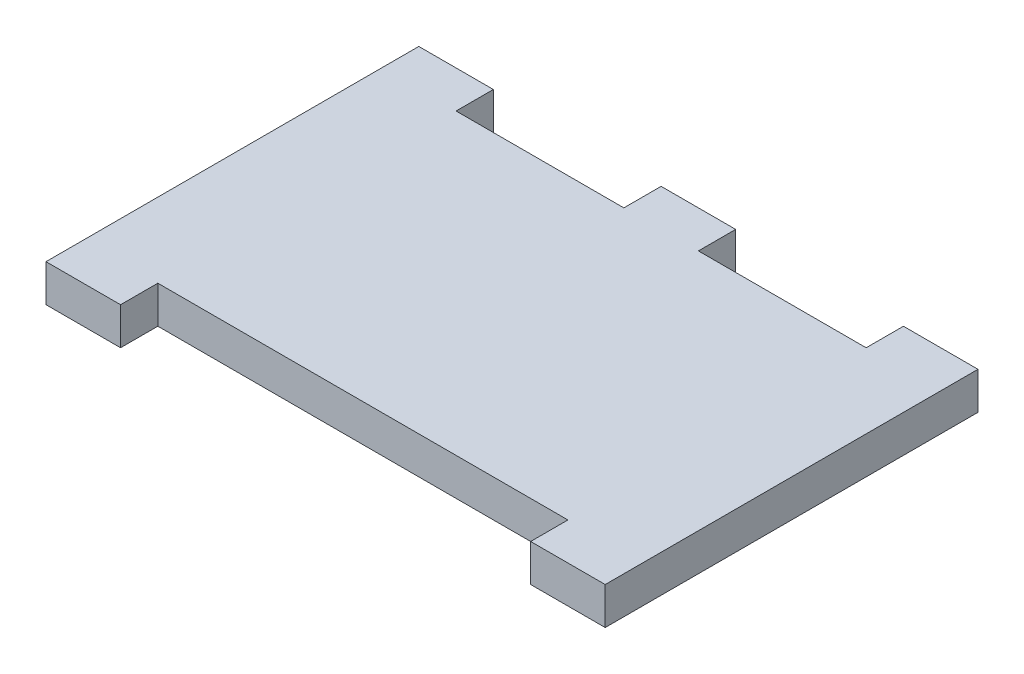
from build123d import *

# Parameters (mm, degrees)
SKETCH1_W           = 114.3
SKETCH1_H           = 76.2
BOSS_EXTRUDE1_DEPTH = 7.62
SKETCH2_W           = 83.82
SKETCH2_H           = 7.62
SKETCH2_W_2         = 34.29
CUT_EXTRUDE1_DEPTH  = 8.62


with BuildPart() as part:
    # Sketch1 → Boss-Extrude1 (new body)
    with BuildSketch(Plane(origin=(0, 0, 0), x_dir=(1, 0, 0), z_dir=(0, 1, 0))):
        with Locations((57.15, 38.1)):
            Rectangle(SKETCH1_W, SKETCH1_H)
    extrude(amount=BOSS_EXTRUDE1_DEPTH)

    # Sketch2 → Cut-Extrude1 (cut, through all)
    with BuildSketch(Plane(origin=(0, 7.62, 0), x_dir=(1, 0, 0), z_dir=(0, 1, 0))):
        with Locations((57.15, 3.81)):
            Rectangle(SKETCH2_W, SKETCH2_H)
        with Locations((32.385, 72.39)):
            Rectangle(SKETCH2_W_2, SKETCH2_H)
        with Locations((81.915, 72.39)):
            Rectangle(SKETCH2_W_2, SKETCH2_H)
    extrude(amount=-CUT_EXTRUDE1_DEPTH, mode=Mode.SUBTRACT)


solid = part.part
